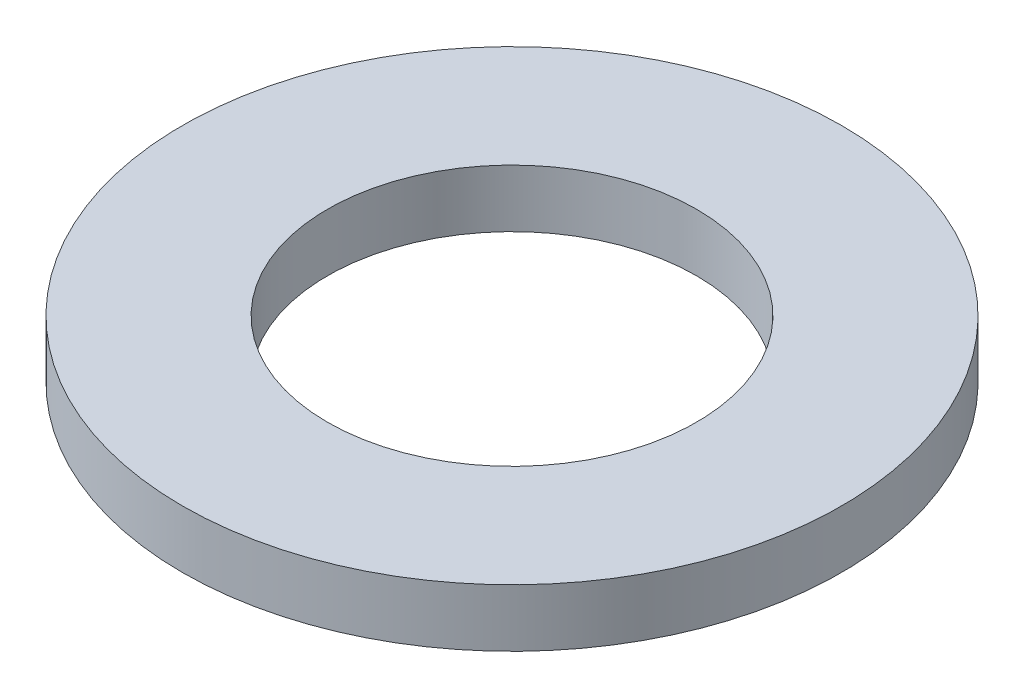
from build123d import *

# Parameters (mm, degrees)
SKETCH1_R           = 28.575
BOSS_EXTRUDE1_DEPTH = 5
SKETCH2_R           = 16
CUT_EXTRUDE1_DEPTH  = 5


with BuildPart() as part:
    # Sketch1 → Boss-Extrude1 (new body)
    with BuildSketch(Plane(origin=(0, 0, 0), x_dir=(1, 0, 0), z_dir=(0, 1, 0))):
        Circle(SKETCH1_R)
    extrude(amount=BOSS_EXTRUDE1_DEPTH)

    # Sketch2 → Cut-Extrude1 (cut)
    with BuildSketch(Plane(origin=(0, 5, 0), x_dir=(1, 0, 0), z_dir=(0, 1, 0))):
        Circle(SKETCH2_R)
    extrude(amount=-CUT_EXTRUDE1_DEPTH, mode=Mode.SUBTRACT)


solid = part.part
